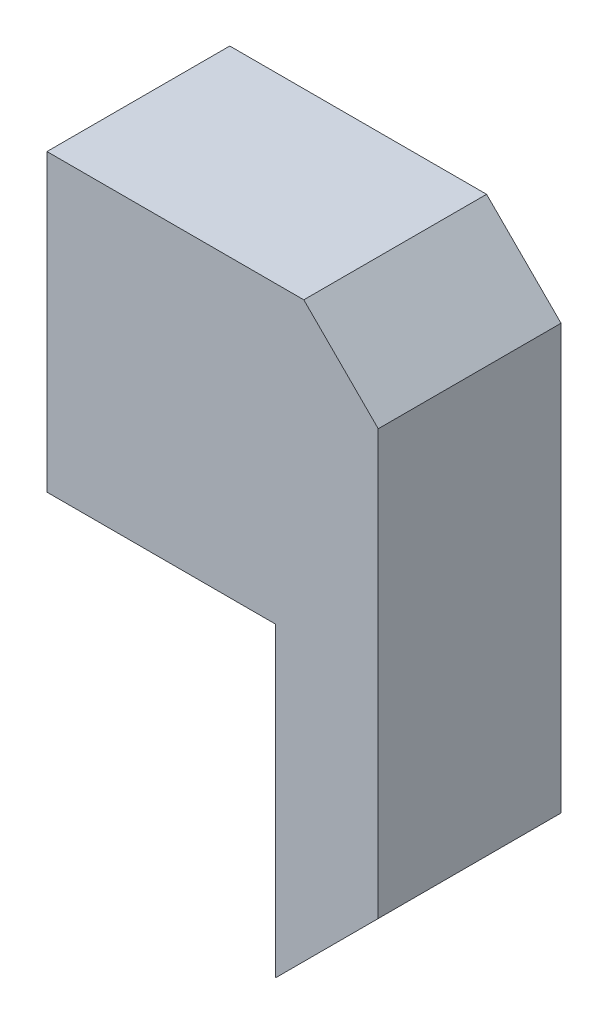
from build123d import *

# Parameters (mm, degrees)
BOSS_EXTRUDE1_DEPTH = 250.825
SHELL1_T            = -1.5875


with BuildPart() as part:
    # Sketch1 → Boss-Extrude1 (new body)
    with BuildSketch(Plane.XY):
        Polygon((0, 0), (0, 404.8125), (352.425, 404.8125), (454.575413377, 302.662086623), (454.575413377, -279.4), (313.287913377, -420.6875), (313.287913377, 0), align=None)
    extrude(amount=-BOSS_EXTRUDE1_DEPTH)

    # Shell1
    shell1_openings = [part.faces().sort_by_distance(p)[0] for p in [
        (313.287913377, -210.34375, -125.4125),
        (156.643956689, 0, -125.4125),
    ]]
    offset(amount=SHELL1_T, openings=shell1_openings, kind=Kind.INTERSECTION)


solid = part.part
